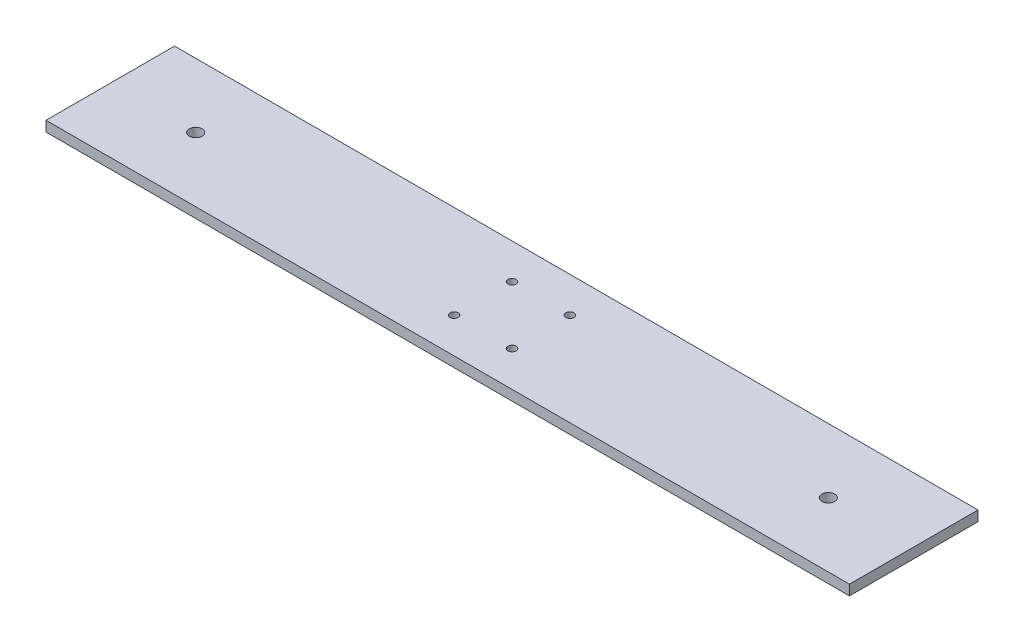
from build123d import *

# Parameters (mm, degrees)
SKETCH1_W           = 250
SKETCH1_H           = 40
SKETCH1_R           = 2
SKETCH1_R_2         = 1.272995864
BOSS_EXTRUDE1_DEPTH = 3.175


with BuildPart() as part:
    # Sketch1 → Boss-Extrude1 (new body)
    with BuildSketch(Plane(origin=(0, 0, 0), x_dir=(1, 0, 0), z_dir=(0, 1, 0))):
        Rectangle(SKETCH1_W, SKETCH1_H)
        with Locations((-98.425, 0)):
            Circle(SKETCH1_R, mode=Mode.SUBTRACT)
        with Locations((98.425, 0)):
            Circle(SKETCH1_R, mode=Mode.SUBTRACT)
        with Locations((-9, 9)):
            Circle(SKETCH1_R_2, mode=Mode.SUBTRACT)
        with Locations((9, 9)):
            Circle(SKETCH1_R_2, mode=Mode.SUBTRACT)
        with Locations((9, -9)):
            Circle(SKETCH1_R_2, mode=Mode.SUBTRACT)
        with Locations((-9, -9)):
            Circle(SKETCH1_R_2, mode=Mode.SUBTRACT)
    extrude(amount=BOSS_EXTRUDE1_DEPTH)


solid = part.part
